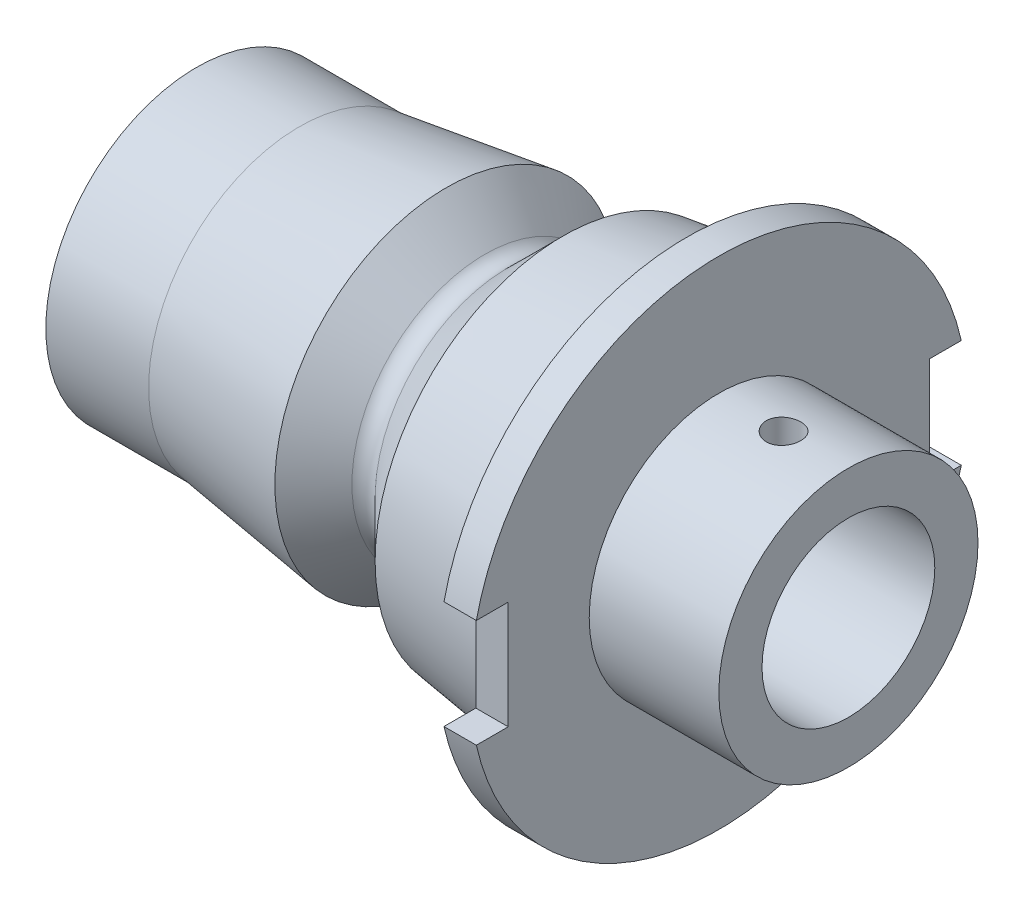
from build123d import *

# Parameters (mm, degrees)
SKETCH3_W                  = 2
SKETCH3_H                  = 5
CUT_EXTRUDE6_DEPTH         = 30.137659458
SKETCH2_R                  = 2.5
CUT_EXTRUDE7_DEPTH         = 30.030211827
SKETCH4_R                  = 6
SKETCH4_R_2                = 4
BOSS_EXTRUDE1_DEPTH        = 6
SKETCH5_R                  = 4
CUT_EXTRUDE8_DEPTH         = 25
M2X0_4_TAPPED_HOLE1_REACH  = 38.645
M2X0_4_TAPPED_HOLE1_BORE_R = 0.8


with BuildPart() as part:
    # Sketch1 → Revolve3 (revolve)
    with BuildSketch(Plane.XY, mode=Mode.PRIVATE) as revolve3_sk:
        with BuildLine():
            Line((0, 0), (0, 6.982))
            Line((0, 6.982), (4.76, 6.982))
            Line((4.76, 6.982), (11.56, 7.937677676))
            Line((11.56, 7.937677676), (13.343138593, 6.154539083))
            ThreePointArc((13.343138593, 6.154539083), (13.880539746, 5.931940237), (14.4179409, 6.154539083))
            Line((14.4179409, 6.154539083), (16.96, 8.696598183))
            Line((16.96, 8.696598183), (22.676500961, 9.5))
            Line((22.676500961, 9.5), (22.676500961, 11.5))
            Line((22.676500961, 11.5), (24.176500961, 11.5))
            Line((24.176500961, 11.5), (24.176500961, 0))
            Line((24.176500961, 0), (0, 0))
        make_face()
    revolve(revolve3_sk.sketch.rotate(Axis((24.176500961, 0, 0), (-1, 0, 0)), 90), axis=Axis((24.176500961, 0, 0), (-1, 0, 0)))

    # Sketch3 → Cut-Extrude6 (cut, through all)
    with BuildSketch(Plane(origin=(24.176500961, 0, 0), x_dir=(0, 0, -1), z_dir=(1, 0, 0))):
        with Locations((-10.75, 0)):
            Rectangle(SKETCH3_W, SKETCH3_H)
        with Locations((10.75, 0)):
            Rectangle(SKETCH3_W, SKETCH3_H)
    extrude(amount=-CUT_EXTRUDE6_DEPTH, mode=Mode.SUBTRACT)

    # Sketch2 → Cut-Extrude7 (cut, through all)
    with BuildSketch(Plane(origin=(0, 0, 0), x_dir=(0, 0, -1), z_dir=(1, 0, 0))):
        Circle(SKETCH2_R)
    extrude(amount=CUT_EXTRUDE7_DEPTH, mode=Mode.SUBTRACT)

    # Sketch4 → Boss-Extrude1 (add)
    with BuildSketch(Plane(origin=(24.176500961, 0, 0), x_dir=(0, 0, -1), z_dir=(1, 0, 0))):
        Circle(SKETCH4_R)
        Circle(SKETCH4_R_2, mode=Mode.SUBTRACT)
    extrude(amount=BOSS_EXTRUDE1_DEPTH)

    # Sketch5 → Cut-Extrude8 (cut)
    with BuildSketch(Plane(origin=(24.176500961, 0, 0), x_dir=(0, 0, -1), z_dir=(1, 0, 0))):
        with Locations(Location((0, 0, 0), (0, 0, 180))):
            Circle(SKETCH5_R)
    extrude(amount=-CUT_EXTRUDE8_DEPTH, mode=Mode.SUBTRACT)

    # M2x0.4 Tapped Hole1 bore → M2x0.4 Tapped Hole1 (cut, up to next)
    with BuildSketch(Plane(origin=(0, 6, 0), x_dir=(1, 0, 0), z_dir=(0, 1, 0)), mode=Mode.PRIVATE) as m2x0_4_tapped_hole1_sk1:
        with Locations((27.176500961, 0)):
            Circle(M2X0_4_TAPPED_HOLE1_BORE_R)
    m2x0_4_tapped_hole1_tool1 = extrude(m2x0_4_tapped_hole1_sk1.sketch, amount=-M2X0_4_TAPPED_HOLE1_REACH, mode=Mode.PRIVATE) & part.part
    add(m2x0_4_tapped_hole1_tool1.solids().sort_by_distance((27.176501, 6, 0))[0], mode=Mode.SUBTRACT)


solid = part.part
